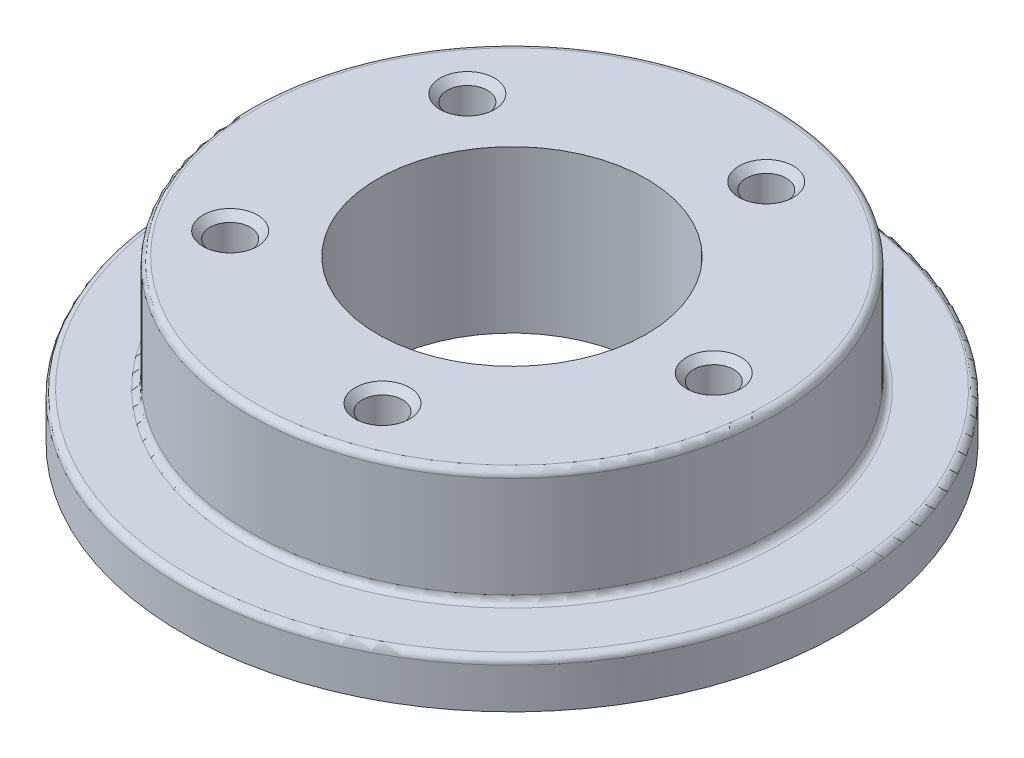
from build123d import *

# Parameters (mm, degrees)
SKETCH1_R          = 24.5
SKETCH1_R_2        = 10
EXTRUDE1_DEPTH     = 3.5
SKETCH1_3_R        = 19.5
SKETCH1_3_R_2      = 10
EXTRUDE2_DEPTH     = 12
CIRPATTERN1_COUNT  = 5
FINISHING_FILLET_R = 0.5


with BuildPart() as part:
    # Sketch1 → Extrude1 (new body)
    with BuildSketch(Plane(origin=(0, 0, 0), x_dir=(1, 0, 0), z_dir=(0, 1, 0))):
        Circle(SKETCH1_R)
        Circle(SKETCH1_R_2, mode=Mode.SUBTRACT)
    extrude(amount=EXTRUDE1_DEPTH)

    # Sketch1_3 → Extrude2 (add)
    with BuildSketch(Plane(origin=(0, 0, 0), x_dir=(1, 0, 0), z_dir=(0, 1, 0))):
        Circle(SKETCH1_3_R)
        Circle(SKETCH1_3_R_2, mode=Mode.SUBTRACT)
    extrude(amount=EXTRUDE2_DEPTH)

    # Sketch3 → Ø3.0 Diameter Hole1 (revolve, cut)
    with BuildSketch(Plane(origin=(15, 12, 0), x_dir=(0, 0, 1), z_dir=(1, 0, 0))):
        Polygon((0, 0), (0, 10.901290929), (1.5, 10), (1.5, 0.525), (2.025, 0), align=None)
    f_3_0_diameter_hole1 = revolve(axis=Axis((15, 18.35, 0), (0, -1, 0)), mode=Mode.SUBTRACT)

    # CirPattern1: Ø3.0 Diameter Hole1 ×5 about axis
    cirpattern1_axis = Axis((0, 12, 0), (0, -1, 0))
    for i in range(1, CIRPATTERN1_COUNT):
        add(f_3_0_diameter_hole1.rotate(cirpattern1_axis, i * 360 / CIRPATTERN1_COUNT), mode=Mode.SUBTRACT)

    # Finishing Fillet
    finishing_fillet_edges = [part.edges().sort_by_distance(p)[0] for p in [
        (-19.5, 12, 0),
        (-19.5, 3.5, 0),
        (-24.5, 3.5, 0),
    ]]
    fillet(finishing_fillet_edges, radius=FINISHING_FILLET_R)


solid = part.part
